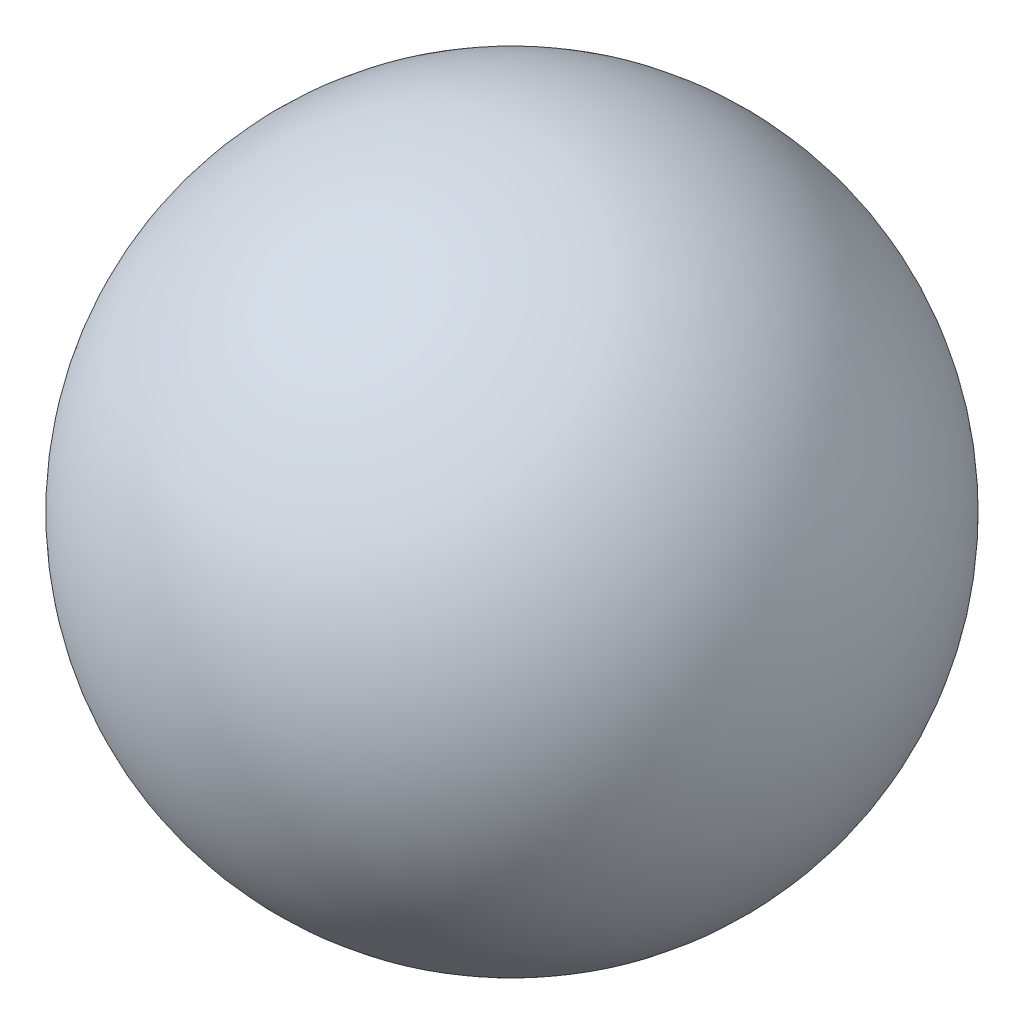
from build123d import *


with BuildPart() as part:
    # Szkic1 → Obrót2 (revolve)
    with BuildSketch(Plane.XY):
        with BuildLine():
            Line((0, 8), (0, 0))
            ThreePointArc((0, 0), (4, 4), (0, 8))
        make_face()
    revolve(axis=Axis((0, 0, 0), (0, 1, 0)))


solid = part.part
